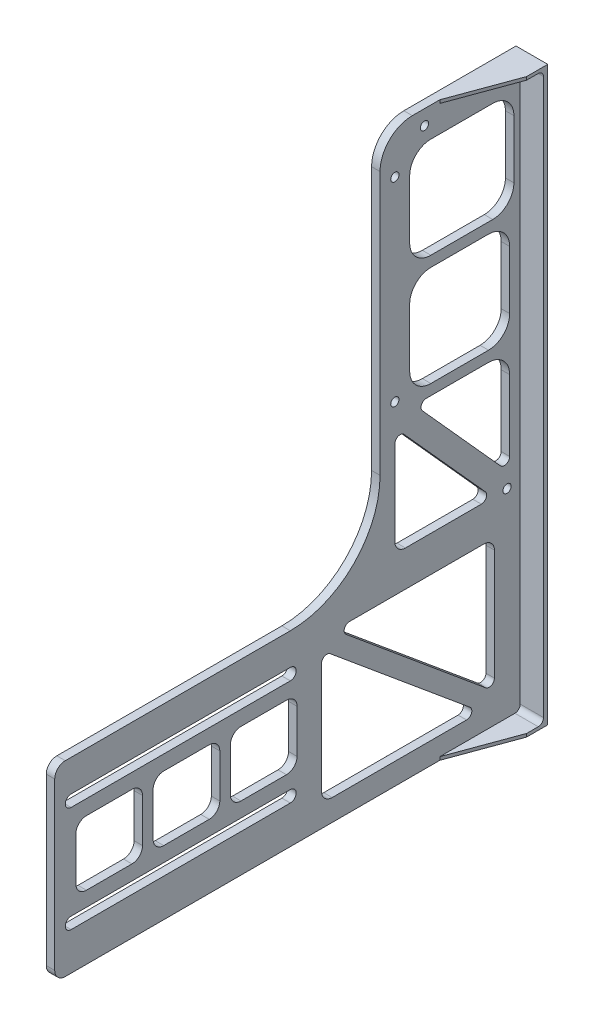
from build123d import *

# Parameters (mm, degrees)
SKETCH1_R           = 1.95
BOSS_EXTRUDE1_DEPTH = 15
CUT_EXTRUDE2_DEPTH  = 16
CUT_EXTRUDE3_DEPTH  = 16
CUT_EXTRUDE4_DEPTH  = 16
CUT_EXTRUDE5_DEPTH  = 16
FILLET1_R           = 5
SKETCH7_W           = 220
SKETCH7_H           = 267.35226683
CUT_EXTRUDE6_DEPTH  = 11
CUT_EXTRUDE7_DEPTH  = 271.35226683
FILLET2_R           = 2.5


with BuildPart() as part:
    # Sketch1 → Boss-Extrude1 (new body)
    with BuildSketch(Plane(origin=(122, 0, 0), x_dir=(0, -1, 0), z_dir=(-1, 0, 0))):
        with BuildLine():
            Line((-67.5, -1.6625), (202.85226683, -1.6625))
            Line((202.85226683, -1.6625), (202.85226683, 220.3375))
            Line((202.85226683, 220.3375), (114.499999998, 220.3375))
            Line((114.499999998, 220.3375), (114.499999998, 108.985233168))
            ThreePointArc((114.499999998, 108.985233168), (102.08199146, 79.005508538), (72.10226683, 66.5875))
            Line((72.10226683, 66.5875), (-52.25, 66.5875))
            ThreePointArc((-52.25, 66.5875), (-63.033378413, 62.120878413), (-67.5, 51.3375))
            Line((-67.5, 51.3375), (-67.5, -1.6625))
        make_face()
        with Locations((-60.5, 6.5875)):
            Circle(SKETCH1_R, mode=Mode.SUBTRACT)
        with Locations((107.5, 6.5875)):
            Circle(SKETCH1_R, mode=Mode.SUBTRACT)
        with Locations((-60.5, 45.5875)):
            Circle(SKETCH1_R, mode=Mode.SUBTRACT)
        with Locations((-46.5, 59.5875)):
            Circle(SKETCH1_R, mode=Mode.SUBTRACT)
        with Locations((45.5, 59.5875)):
            Circle(SKETCH1_R, mode=Mode.SUBTRACT)
        Polygon((42.95, 15.7375), (42.95, 13.2375), (40.95, 11.3375), (33.95, 11.3375), (31.95, 13.2375), (31.95, 15.7375), align=None, mode=Mode.SUBTRACT)
        with BuildLine():
            Line((30.95, 11.3375), (17.5, 11.3375))
            Line((17.5, 11.3375), (17.5, 13.9375))
            ThreePointArc((17.5, 13.9375), (24.225, 16.3375), (30.95, 13.9375))
            Line((30.95, 13.9375), (30.95, 11.3375))
        make_face(mode=Mode.SUBTRACT)
    extrude(amount=-BOSS_EXTRUDE1_DEPTH)

    # Sketch2 → Cut-Extrude2 (cut, through all)
    with BuildSketch(Plane(origin=(137, 0, 0), x_dir=(0, 0, -1), z_dir=(1, 0, 0))):
        with BuildLine():
            Line((-42.5875, 53.5), (-13.3375, 53.5))
            ThreePointArc((-13.3375, 53.5), (-6.266432188, 50.571067812), (-3.3375, 43.5))
            Line((-3.3375, 43.5), (-3.3375, 16))
            ThreePointArc((-3.3375, 16), (-6.266432188, 8.928932188), (-13.3375, 6))
            Line((-13.3375, 6), (-42.5875, 6))
            ThreePointArc((-42.5875, 6), (-49.658567812, 8.928932188), (-52.5875, 16))
            Line((-52.5875, 16), (-52.5875, 43.5))
            ThreePointArc((-52.5875, 43.5), (-49.658567812, 50.571067812), (-42.5875, 53.5))
        make_face()
        with BuildLine():
            Line((-42.5875, -46.5), (-15.3375, -46.5))
            ThreePointArc((-15.3375, -46.5), (-8.266432188, -43.571067812), (-5.3375, -36.5))
            Line((-5.3375, -36.5), (-5.3375, -9))
            ThreePointArc((-5.3375, -9), (-8.266432188, -1.928932188), (-15.3375, 1))
            Line((-15.3375, 1), (-42.5875, 1))
            ThreePointArc((-42.5875, 1), (-49.658567812, -1.928932188), (-52.5875, -9))
            Line((-52.5875, -9), (-52.5875, -36.5))
            ThreePointArc((-52.5875, -36.5), (-49.658567812, -43.571067812), (-42.5875, -46.5))
        make_face()
        with BuildLine():
            Line((-55.22929809, -61.015037849), (-16.864289826, -103.641109909))
            ThreePointArc((-16.864289826, -103.641109909), (-16.438731405, -106.33063253), (-18.722491736, -107.81355891))
            Line((-18.722491736, -107.81355891), (-54.5875, -107.81355891))
            ThreePointArc((-54.5875, -107.81355891), (-58.123033906, -106.349092816), (-59.5875, -102.81355891))
            Line((-59.5875, -102.81355891), (-59.5875, -62.68748685))
            ThreePointArc((-59.5875, -62.68748685), (-57.983182763, -60.353444779), (-55.22929809, -61.015037849))
        make_face()
        with BuildLine():
            Line((-44.725753318, -51.5), (-15.3375, -51.5))
            ThreePointArc((-15.3375, -51.5), (-8.266432188, -54.428932188), (-5.3375, -61.5))
            Line((-5.3375, -61.5), (-5.3375, -94.985299242))
            ThreePointArc((-5.3375, -94.985299242), (-6.941817237, -97.319341313), (-9.69570191, -96.657748243))
            Line((-9.69570191, -96.657748243), (-46.583955228, -55.672449001))
            ThreePointArc((-46.583955228, -55.672449001), (-47.00951365, -52.98292638), (-44.725753318, -51.5))
        make_face()
    extrude(amount=-CUT_EXTRUDE2_DEPTH, mode=Mode.SUBTRACT)

    # Sketch3 → Cut-Extrude3 (cut, through all)
    with BuildSketch(Plane(origin=(137, 0, 0), x_dir=(0, 0, -1), z_dir=(1, 0, 0))):
        with BuildLine():
            Line((-212.5875, -129.499999998), (-108.985233168, -129.499999998))
            ThreePointArc((-108.985233168, -129.499999998), (-106.235233168, -132.249999998), (-108.985233168, -134.999999998))
            Line((-108.985233168, -134.999999998), (-212.5875, -134.999999998))
            ThreePointArc((-212.5875, -134.999999998), (-215.3375, -132.249999998), (-212.5875, -129.499999998))
        make_face()
        with BuildLine():
            Line((-212.5875, -179.499999998), (-108.985233168, -179.499999998))
            ThreePointArc((-108.985233168, -179.499999998), (-106.235233168, -182.249999998), (-108.985233168, -184.999999998))
            Line((-108.985233168, -184.999999998), (-212.5875, -184.999999998))
            ThreePointArc((-212.5875, -184.999999998), (-215.3375, -182.249999998), (-212.5875, -179.499999998))
        make_face()
    extrude(amount=-CUT_EXTRUDE3_DEPTH, mode=Mode.SUBTRACT)

    # Sketch4 → Cut-Extrude4 (cut, through all)
    with BuildSketch(Plane(origin=(137, 0, 0), x_dir=(0, 0, -1), z_dir=(1, 0, 0))):
        with BuildLine():
            Line((-94.235233168, -187.642635713), (-94.235233168, -135.242622679))
            ThreePointArc((-94.235233168, -135.242622679), (-92.796770819, -132.97918772), (-90.136722915, -133.320445536))
            Line((-90.136722915, -133.320445536), (-24.120536911, -188.22045857))
            ThreePointArc((-24.120536911, -188.22045857), (-23.367936485, -190.992505451), (-25.719047164, -192.642635713))
            Line((-25.719047164, -192.642635713), (-89.235233168, -192.642635713))
            ThreePointArc((-89.235233168, -192.642635713), (-92.770767074, -191.178169619), (-94.235233168, -187.642635713))
        make_face()
        with BuildLine():
            Line((-12.547131117, -129.709631116), (-12.547131117, -182.109644149))
            ThreePointArc((-12.547131117, -182.109644149), (-13.985593467, -184.373079109), (-16.64564137, -184.031821292))
            Line((-16.64564137, -184.031821292), (-82.661827375, -129.131808259))
            ThreePointArc((-82.661827375, -129.131808259), (-83.414427801, -126.359761378), (-81.063317121, -124.709631116))
            Line((-81.063317121, -124.709631116), (-17.547131117, -124.709631116))
            ThreePointArc((-17.547131117, -124.709631116), (-14.011597211, -126.17409721), (-12.547131117, -129.709631116))
        make_face()
    extrude(amount=-CUT_EXTRUDE4_DEPTH, mode=Mode.SUBTRACT)

    # Sketch5 → Cut-Extrude5 (cut, through all)
    with BuildSketch(Plane(origin=(137, 0, 0), x_dir=(0, 0, -1), z_dir=(1, 0, 0))):
        with BuildLine():
            Line((-210.3375, -146.999999998), (-210.3375, -167.499999998))
            ThreePointArc((-210.3375, -167.499999998), (-208.873033906, -171.035533904), (-205.3375, -172.499999998))
            Line((-205.3375, -172.499999998), (-183.830323645, -172.499999998))
            ThreePointArc((-183.830323645, -172.499999998), (-180.294789739, -171.035533904), (-178.830323645, -167.499999998))
            Line((-178.830323645, -167.499999998), (-178.830323645, -146.999999998))
            ThreePointArc((-178.830323645, -146.999999998), (-180.294789739, -143.464466093), (-183.830323645, -141.999999998))
            Line((-183.830323645, -141.999999998), (-205.3375, -141.999999998))
            ThreePointArc((-205.3375, -141.999999998), (-208.873033906, -143.464466093), (-210.3375, -146.999999998))
        make_face()
        with BuildLine():
            Line((-173.830323645, -146.999999998), (-173.830323645, -167.499999998))
            ThreePointArc((-173.830323645, -167.499999998), (-172.365857551, -171.035533904), (-168.830323645, -172.499999998))
            Line((-168.830323645, -172.499999998), (-147.323147289, -172.499999998))
            ThreePointArc((-147.323147289, -172.499999998), (-143.787613384, -171.035533904), (-142.323147289, -167.499999998))
            Line((-142.323147289, -167.499999998), (-142.323147289, -146.999999998))
            ThreePointArc((-142.323147289, -146.999999998), (-143.787613384, -143.464466093), (-147.323147289, -141.999999998))
            Line((-147.323147289, -141.999999998), (-168.830323645, -141.999999998))
            ThreePointArc((-168.830323645, -141.999999998), (-172.365857551, -143.464466093), (-173.830323645, -146.999999998))
        make_face()
        with BuildLine():
            Line((-137.323147289, -146.999999998), (-137.323147289, -167.499999998))
            ThreePointArc((-137.323147289, -167.499999998), (-135.858681195, -171.035533904), (-132.323147289, -172.499999998))
            Line((-132.323147289, -172.499999998), (-110.815970934, -172.499999998))
            ThreePointArc((-110.815970934, -172.499999998), (-107.280437028, -171.035533904), (-105.815970934, -167.499999998))
            Line((-105.815970934, -167.499999998), (-105.815970934, -146.999999998))
            ThreePointArc((-105.815970934, -146.999999998), (-107.280437028, -143.464466093), (-110.815970934, -141.999999998))
            Line((-110.815970934, -141.999999998), (-132.323147289, -141.999999998))
            ThreePointArc((-132.323147289, -141.999999998), (-135.858681195, -143.464466093), (-137.323147289, -146.999999998))
        make_face()
    extrude(amount=-CUT_EXTRUDE5_DEPTH, mode=Mode.SUBTRACT)

    # Fillet1
    fillet1_edges = [part.edges().sort_by_distance(p)[0] for p in [
        (129.5, -114.499999998, 220.3375),
        (129.5, -202.85226683, 220.3375),
    ]]
    fillet(fillet1_edges, radius=FILLET1_R)

    # Sketch7 → Cut-Extrude6 (cut)
    with BuildSketch(Plane(origin=(137, 0, 0), x_dir=(0, 0, -1), z_dir=(1, 0, 0))):
        with Locations((-110.3375, -67.676133415)):
            Rectangle(SKETCH7_W, SKETCH7_H)
    extrude(amount=-CUT_EXTRUDE6_DEPTH, mode=Mode.SUBTRACT)

    # Sketch8 → Cut-Extrude7 (cut, through all)
    with BuildSketch(Plane.XZ.offset(202.85226683)):
        Polygon((137, 54.353248627), (137, 242.443718096), (126, 242.443718096), (126, 38.3375), (137, 8.3375), align=None)
    extrude(amount=-CUT_EXTRUDE7_DEPTH, mode=Mode.SUBTRACT)

    # Fillet2
    fillet2_edges = [part.edges().sort_by_distance(p)[0] for p in [
        (131.5, 66, 0.3375),
        (131.5, -201.35226683, 0.3375),
    ]]
    fillet(fillet2_edges, radius=FILLET2_R)


solid = part.part
